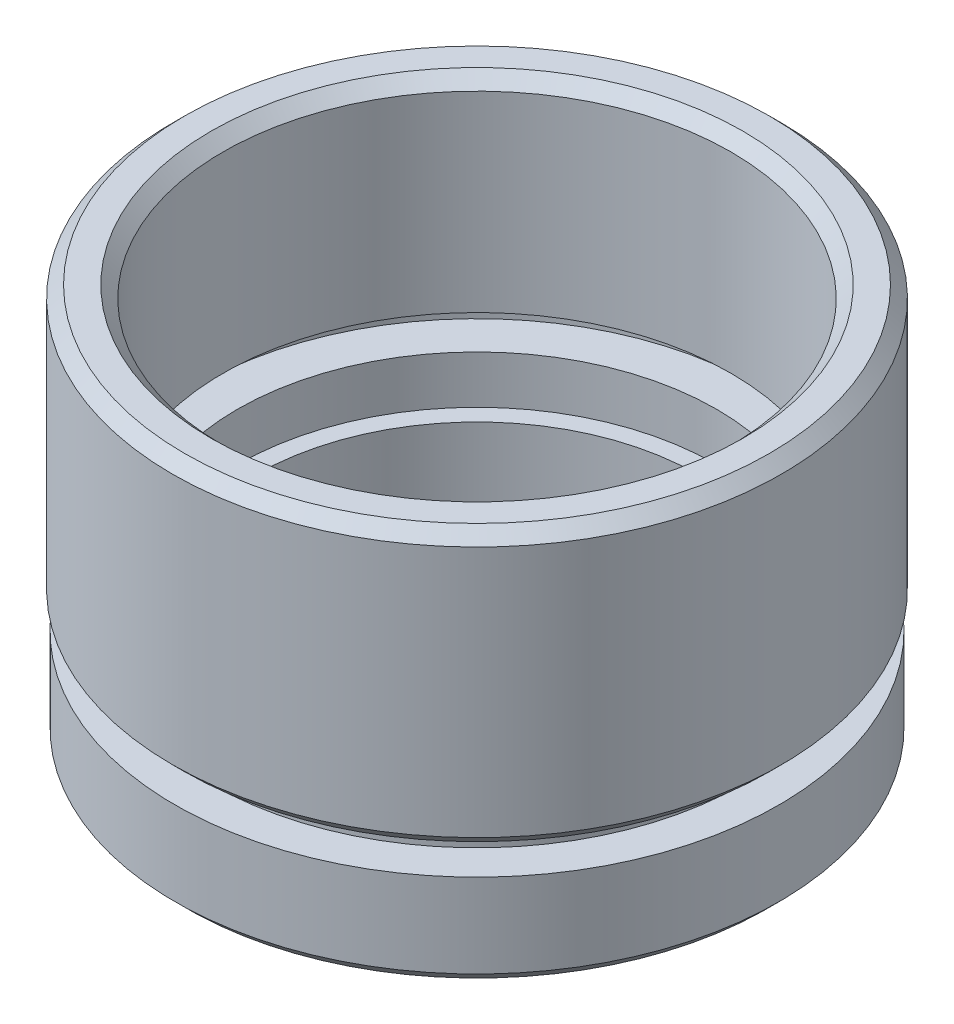
from build123d import *

# Parameters (mm, degrees)
CHAMFER_1_SIZE = 0.5


with BuildPart() as part:
    # 草图1 → 旋转1 (revolve)
    with BuildSketch(Plane.XY, mode=Mode.PRIVATE) as revolve_1_sk:
        Polygon((9.25, 0), (12.6, 0), (12.6, 4), (11.1, 4), (11.1, 5), (12.7, 5), (12.7, 16.5), (10.6, 16.5), (10.6, 8), (11.7, 8), (11.7, 7), (10, 7), (10, 5), (9.25, 5), align=None)
    revolve(revolve_1_sk.sketch.rotate(Axis((0, 0, 0), (0, 1, 0)), 90), axis=Axis((0, 0, 0), (0, 1, 0)))  # turned: the seam where the file's is

    # 倒角1
    chamfer_1_edges = [part.edges().sort_by_distance(p)[0] for p in [
        (0, 16.5, 10.6),
        (0, 16.5, 12.7),
        (0, 5, 12.7),
        (0, 0, 12.6),
    ]]
    chamfer(chamfer_1_edges, length=CHAMFER_1_SIZE)


solid = part.part
